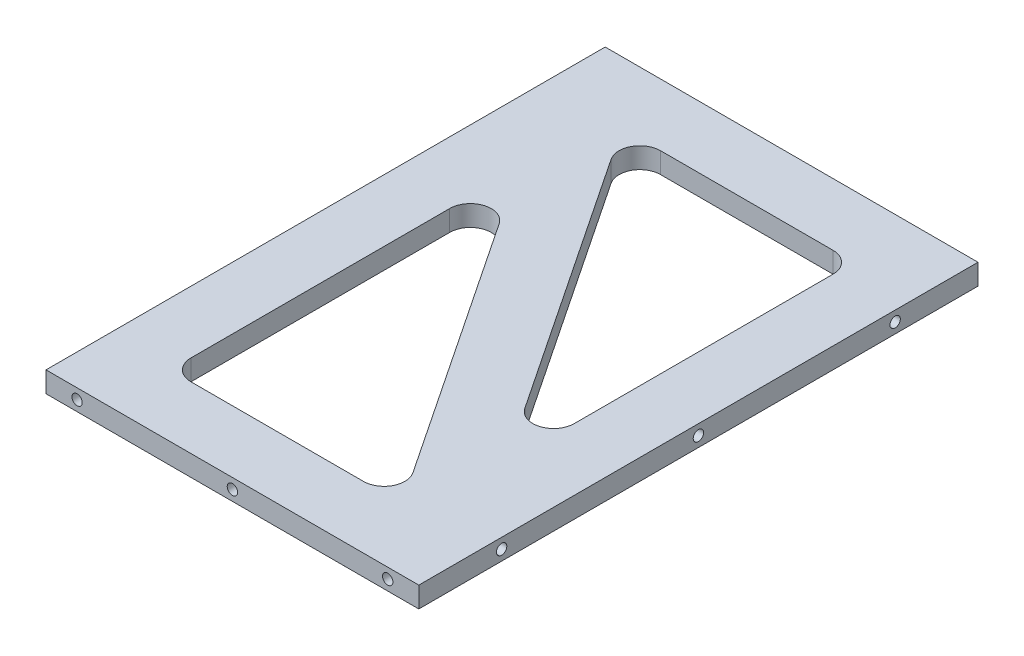
from build123d import *

# Parameters (mm, degrees)
SKETCH1_W             = 180
SKETCH1_H             = 270
BOSS_EXTRUDE1_DEPTH   = 10
CUT_EXTRUDE1_DEPTH    = 11
FILLET1_R             = 10
M6_TAPPED_HOLE1_D     = 5
M6_TAPPED_HOLE1_DEPTH = 23
M6_TAPPED_HOLE1_TIP   = 1.502151548
M6_TAPPED_HOLE2_D     = 5
M6_TAPPED_HOLE2_DEPTH = 20
M6_TAPPED_HOLE2_TIP   = 1.502151548
M6_TAPPED_HOLE3_D     = 5
M6_TAPPED_HOLE3_DEPTH = 20
M6_TAPPED_HOLE3_TIP   = 1.502151548


with BuildPart() as part:
    # Sketch1 → Boss-Extrude1 (new body)
    with BuildSketch(Plane(origin=(0, 0, 0), x_dir=(1, 0, 0), z_dir=(0, 1, 0))):
        with Locations((90, 135)):
            Rectangle(SKETCH1_W, SKETCH1_H)
    extrude(amount=BOSS_EXTRUDE1_DEPTH)

    # Sketch2 → Cut-Extrude1 (cut, through all)
    with BuildSketch(Plane(origin=(0, 10, 0), x_dir=(1, 0, 0), z_dir=(0, 1, 0))):
        Polygon((38.027756377, 240), (150, 240), (150, 72.041634566), align=None)
        Polygon((30, 197.958365434), (30, 30), (141.972243623, 30), align=None)
    extrude(amount=-CUT_EXTRUDE1_DEPTH, mode=Mode.SUBTRACT)

    # Fillet1
    fillet1_edges = [part.edges().sort_by_distance(p)[0] for p in [
        (150, 5, -72.041634566),
        (38.027756377, 5, -240),
        (150, 5, -240),
        (30, 5, -197.958365434),
        (141.972243623, 5, -30),
        (30, 5, -30),
    ]]
    fillet(fillet1_edges, radius=FILLET1_R)

    # M6 Tapped Hole1
    with Locations(Plane.XY):
        with Locations((15, 5), (90, 5), (165, 5)):
            Hole(M6_TAPPED_HOLE1_D / 2, depth=M6_TAPPED_HOLE1_DEPTH)
            with Locations((0, 0, -(M6_TAPPED_HOLE1_DEPTH + M6_TAPPED_HOLE1_TIP / 2))):  # 118° drill point
                Cone(0, M6_TAPPED_HOLE1_D / 2, M6_TAPPED_HOLE1_TIP, mode=Mode.SUBTRACT)

    # M6 Tapped Hole2
    with Locations(Plane(origin=(0, 0, -270), x_dir=(-1, 0, 0), z_dir=(0, 0, -1))):
        with Locations((-165, 5), (-90, 5), (-15, 5)):
            Hole(M6_TAPPED_HOLE2_D / 2, depth=M6_TAPPED_HOLE2_DEPTH)
            with Locations((0, 0, -(M6_TAPPED_HOLE2_DEPTH + M6_TAPPED_HOLE2_TIP / 2))):  # 118° drill point
                Cone(0, M6_TAPPED_HOLE2_D / 2, M6_TAPPED_HOLE2_TIP, mode=Mode.SUBTRACT)

    # M6 Tapped Hole3
    with Locations(Plane(origin=(180, 0, 0), x_dir=(0, 0, -1), z_dir=(1, 0, 0))):
        with Locations((40, 5), (135, 5), (230, 5)):
            Hole(M6_TAPPED_HOLE3_D / 2, depth=M6_TAPPED_HOLE3_DEPTH)
            with Locations((0, 0, -(M6_TAPPED_HOLE3_DEPTH + M6_TAPPED_HOLE3_TIP / 2))):  # 118° drill point
                Cone(0, M6_TAPPED_HOLE3_D / 2, M6_TAPPED_HOLE3_TIP, mode=Mode.SUBTRACT)


solid = part.part
